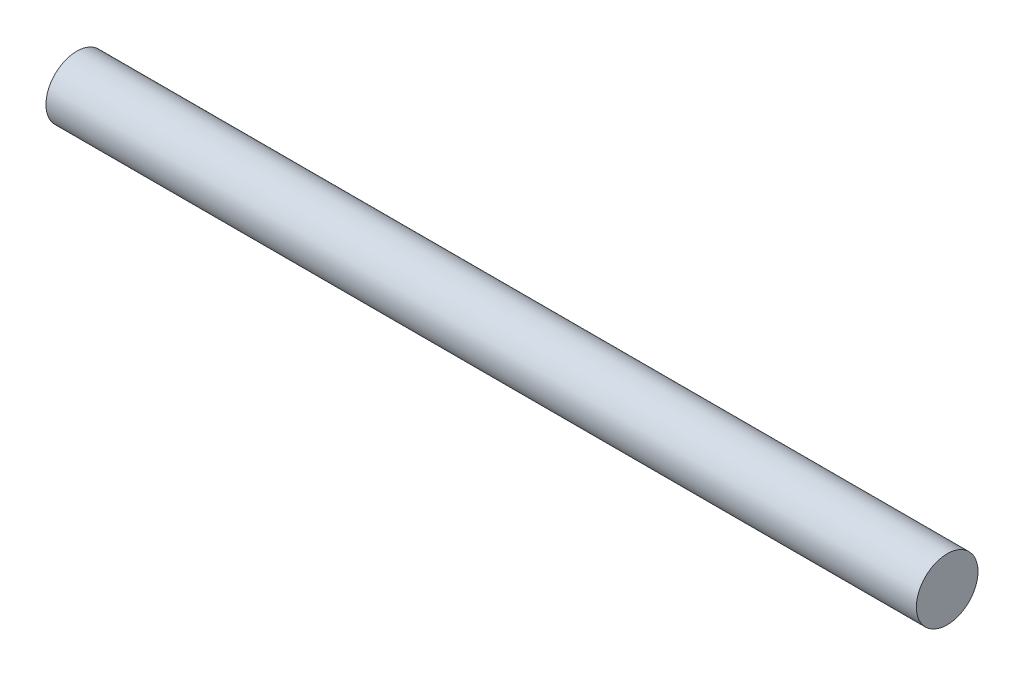
from build123d import *

# Parameters (mm, degrees)
SKETCH1_R           = 25.365
BOSS_EXTRUDE1_DEPTH = 716.28


with BuildPart() as part:
    # Sketch1 → Boss-Extrude1 (new body)
    with BuildSketch(Plane(origin=(0, 0, 0), x_dir=(0, 0, -1), z_dir=(1, 0, 0))):
        Circle(SKETCH1_R)
    extrude(amount=BOSS_EXTRUDE1_DEPTH)


solid = part.part
